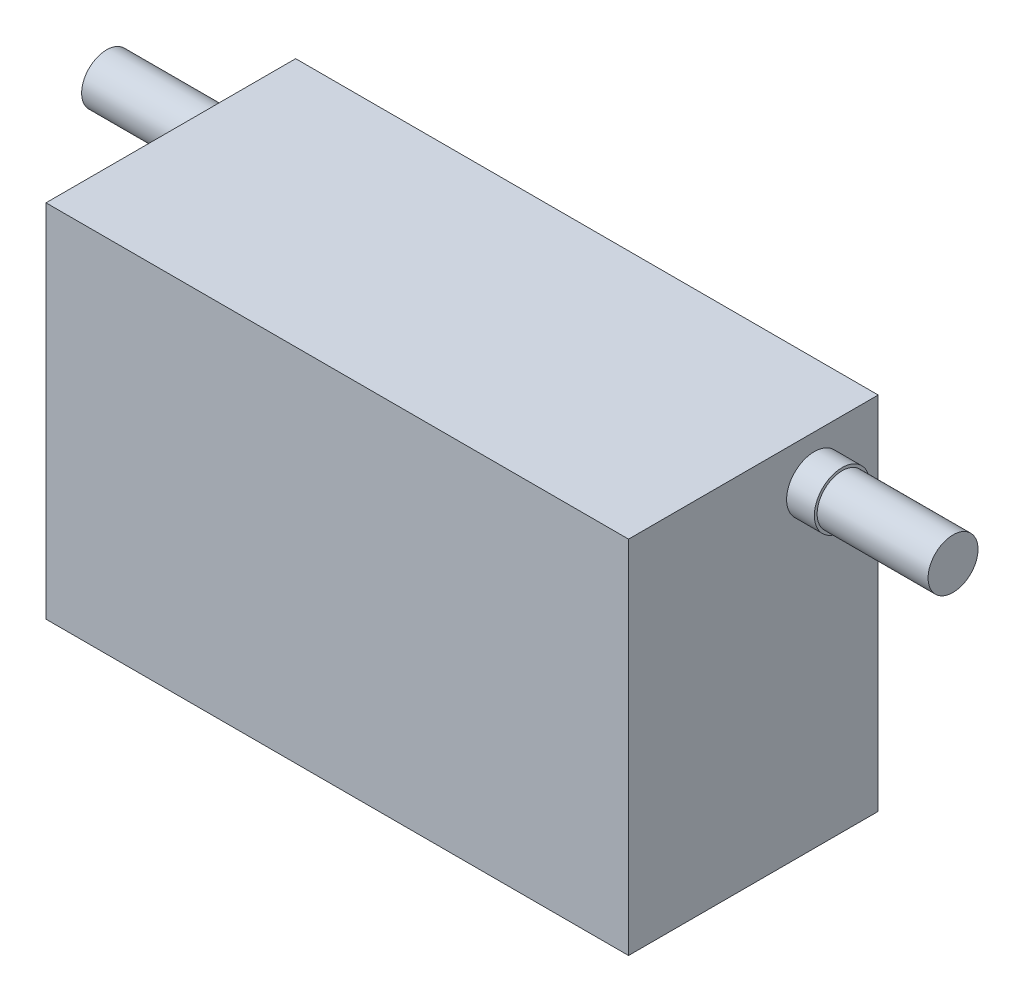
from build123d import *

# Parameters (mm, degrees)
SKETCH1_W           = 105
SKETCH1_H           = 65
BOSS_EXTRUDE1_DEPTH = 45
SKETCH2_R           = 5
BOSS_EXTRUDE2_DEPTH = 5
SKETCH3_R           = 4.5
BOSS_EXTRUDE3_DEPTH = 20
SKETCH4_R           = 5
BOSS_EXTRUDE4_DEPTH = 5
SKETCH5_R           = 4.5
BOSS_EXTRUDE5_DEPTH = 20


with BuildPart() as part:
    # Sketch1 → Boss-Extrude1 (new body)
    with BuildSketch(Plane.XY):
        Rectangle(SKETCH1_W, SKETCH1_H)
    extrude(amount=BOSS_EXTRUDE1_DEPTH)

    # Sketch2 → Boss-Extrude2 (add)
    with BuildSketch(Plane.ZY.offset(52.5)):
        with Locations((9.080491803, 21.421132833)):
            Circle(SKETCH2_R)
    extrude(amount=BOSS_EXTRUDE2_DEPTH)

    # Sketch3 → Boss-Extrude3 (add)
    with BuildSketch(Plane.ZY.offset(57.5)):
        with Locations((9.080491803, 21.421132833)):
            Circle(SKETCH3_R)
    extrude(amount=BOSS_EXTRUDE3_DEPTH)

    # Sketch4 → Boss-Extrude4 (add)
    with BuildSketch(Plane(origin=(52.5, 0, 0), x_dir=(0, 0, -1), z_dir=(1, 0, 0))):
        with Locations((-11.51313285, 24.423590695)):
            Circle(SKETCH4_R)
    extrude(amount=BOSS_EXTRUDE4_DEPTH)

    # Sketch5 → Boss-Extrude5 (add)
    with BuildSketch(Plane(origin=(57.5, 0, 0), x_dir=(0, 0, -1), z_dir=(1, 0, 0))):
        with Locations((-11.51313285, 24.423590695)):
            Circle(SKETCH5_R)
    extrude(amount=BOSS_EXTRUDE5_DEPTH)


solid = part.part
